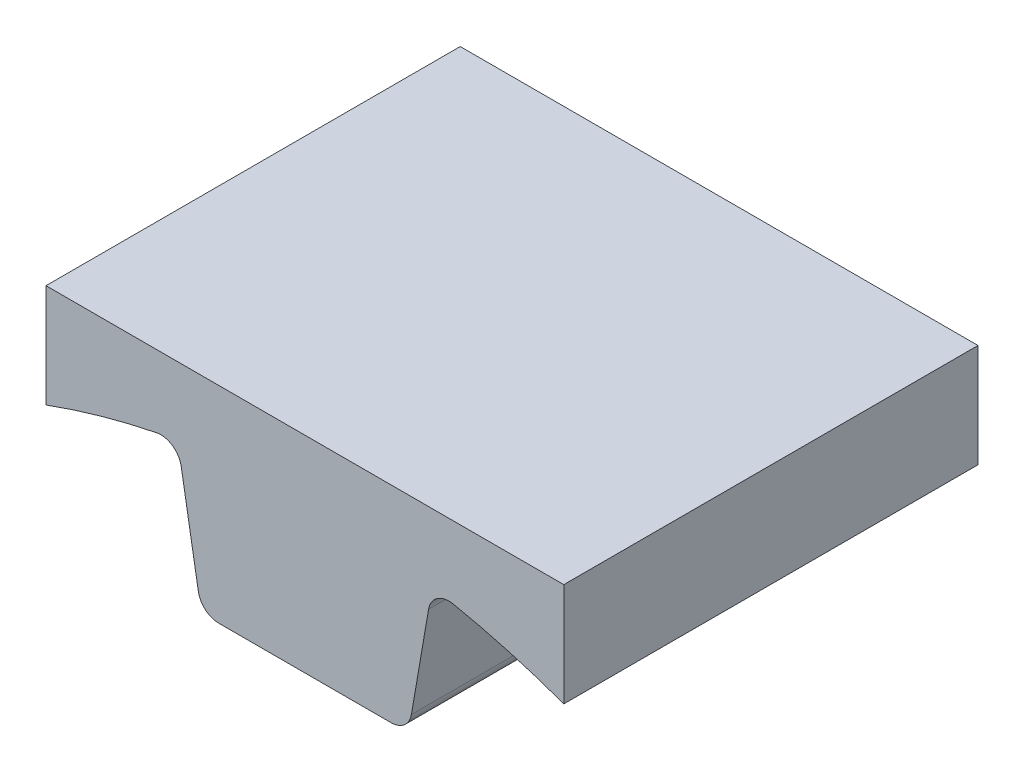
from build123d import *

# Parameters (mm, degrees)
BOSS_EXTRUDE1_DEPTH = 50.8
FILLET1_R           = 2.54


with BuildPart() as part:
    # Sketch1 → Boss-Extrude1 (new body)
    with BuildSketch(Plane.XY):
        with BuildLine():
            Line((-12.7, 73.846320157), (12.7, 73.846320157))
            Line((12.7, 73.846320157), (15.605843118, 90.742841512))
            ThreePointArc((15.605843118, 90.742841512), (23.776020133, 88.952270863), (31.75, 86.427675689))
            Line((31.75, 86.427675689), (31.75, 99.102275689))
            Line((31.75, 99.102275689), (-31.75, 99.102275689))
            Line((-31.75, 99.102275689), (-31.75, 86.427675689))
            ThreePointArc((-31.75, 86.427675689), (-23.776020133, 88.952270863), (-15.605843118, 90.742841512))
            Line((-15.605843118, 90.742841512), (-12.7, 73.846320157))
        make_face()
    extrude(amount=BOSS_EXTRUDE1_DEPTH)

    # Fillet1
    fillet1_edges = [part.edges().sort_by_distance(p)[0] for p in [
        (12.7, 73.846320157, 25.4),
        (-12.7, 73.846320157, 25.4),
        (-15.605843118, 90.742841512, 25.4),
        (15.605843118, 90.742841512, 25.4),
    ]]
    fillet(fillet1_edges, radius=FILLET1_R)


solid = part.part
